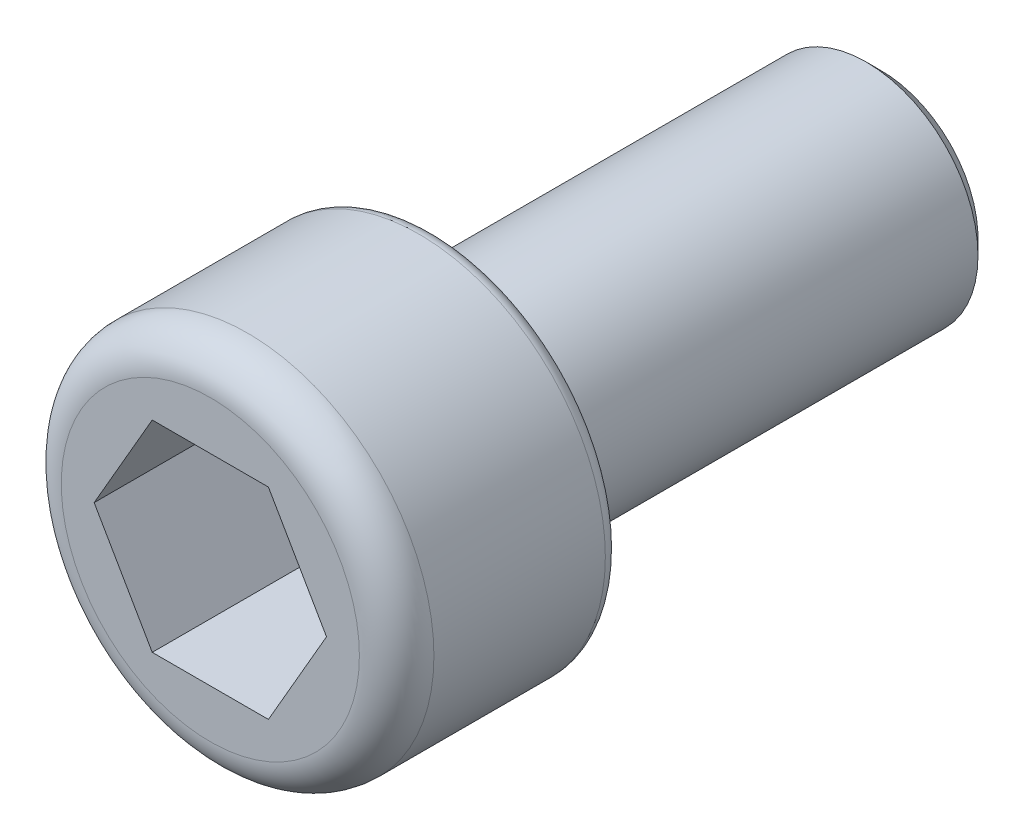
from build123d import *

# Parameters (mm, degrees)
SKETCH_1_R          = 2.5
EXTRUDE_1_DEPTH     = 3
FILLET_1_R          = 0.5
CUT_EXTRUDE_1_DEPTH = 2
SKETCH_3_R          = 1.5
EXTRUDE_2_DEPTH     = 6
CHAMFER_1_SIZE      = 0.2
FILLET_2_R          = 0.2


with BuildPart() as part:
    # 草图1 → 凸台-拉伸1 (new body)
    with BuildSketch(Plane.XY):
        Circle(SKETCH_1_R)
    extrude(amount=EXTRUDE_1_DEPTH)

    # 圆角1
    fillet_1_edges = [part.edges().sort_by_distance(p)[0] for p in [
        (-2.5, 0, 3),
    ]]
    fillet(fillet_1_edges, radius=FILLET_1_R)

    # 草图2 → 切除-拉伸1 (cut)
    with BuildSketch(Plane.XY.offset(3)):
        Polygon((1.558845727, 0), (0.779422863, 1.35), (-0.779422863, 1.35), (-1.558845727, 0), (-0.779422863, -1.35), (0.779422863, -1.35), align=None)
    extrude(amount=-CUT_EXTRUDE_1_DEPTH, mode=Mode.SUBTRACT)

    # 草图3 → 凸台-拉伸2 (add)
    with BuildSketch(Plane(origin=(0, 0, 0), x_dir=(-1, 0, 0), z_dir=(0, 0, -1))):
        Circle(SKETCH_3_R)
    extrude(amount=EXTRUDE_2_DEPTH)

    # 倒角1
    chamfer_1_edges = [part.edges().sort_by_distance(p)[0] for p in [
        (1.5, 0, -6),
    ]]
    chamfer(chamfer_1_edges, length=CHAMFER_1_SIZE)

    # 圆角2
    fillet_2_edges = [part.edges().sort_by_distance(p)[0] for p in [
        (-2.5, 0, 0),
    ]]
    fillet(fillet_2_edges, radius=FILLET_2_R)


solid = part.part
